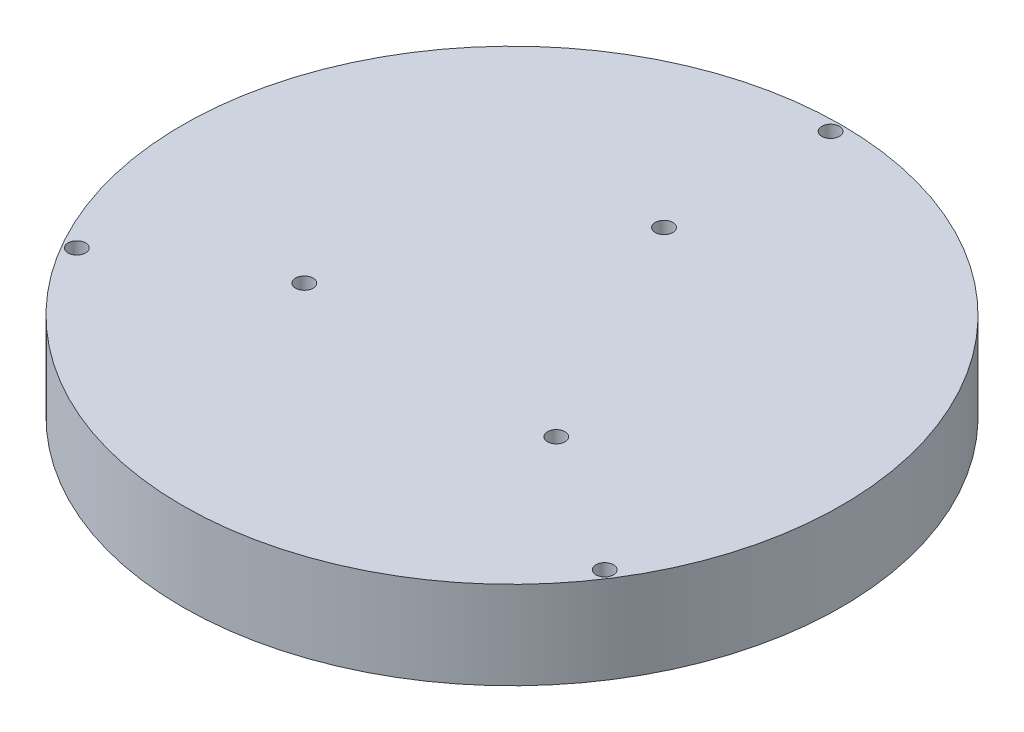
from build123d import *

# Parameters (mm, degrees)
SKETCH3_R           = 37.5
SKETCH3_R_2         = 1
BOSS_EXTRUDE2_DEPTH = 10


with BuildPart() as part:
    # Sketch3 → Boss-Extrude2 (new body)
    with BuildSketch(Plane(origin=(0, 0, 0), x_dir=(1, 0, 0), z_dir=(0, 1, 0))):
        Circle(SKETCH3_R)
        with Locations((0, 17.3)):
            Circle(SKETCH3_R_2, mode=Mode.SUBTRACT)
        with Locations((0, 36.25)):
            Circle(SKETCH3_R_2, mode=Mode.SUBTRACT)
        with Locations((14.488449759, -9.45382587)):
            Circle(SKETCH3_R_2, mode=Mode.SUBTRACT)
        with Locations((30.358745883, -19.809317213)):
            Circle(SKETCH3_R_2, mode=Mode.SUBTRACT)
        with Locations((-14.982239485, -8.65)):
            Circle(SKETCH3_R_2, mode=Mode.SUBTRACT)
        with Locations((-31.393420887, -18.125)):
            Circle(SKETCH3_R_2, mode=Mode.SUBTRACT)
    extrude(amount=BOSS_EXTRUDE2_DEPTH)


solid = part.part
